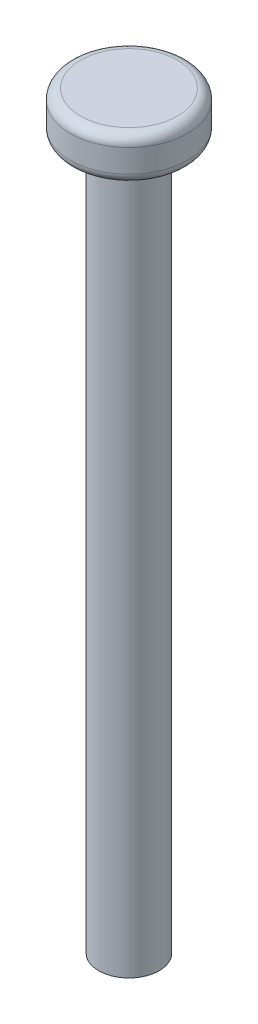
from build123d import *

# Parameters (mm, degrees)
SKETCH1_R           = 3
BOSS_EXTRUDE1_DEPTH = 70
SKETCH2_R           = 5.8
BOSS_EXTRUDE2_DEPTH = 4.3
FILLET1_R           = 1


with BuildPart() as part:
    # Sketch1 → Boss-Extrude1 (new body)
    with BuildSketch(Plane(origin=(0, 0, 0), x_dir=(1, 0, 0), z_dir=(0, 1, 0))):
        with Locations(Location((0, 0, 0), (0, 0, 270))):  # turned: the seam where the file's is
            Circle(SKETCH1_R)
    extrude(amount=BOSS_EXTRUDE1_DEPTH)

    # Sketch2 → Boss-Extrude2 (add)
    with BuildSketch(Plane(origin=(0, 70, 0), x_dir=(1, 0, 0), z_dir=(0, 1, 0))):
        with Locations(Location((0, 0, 0), (0, 0, 270))):  # turned: the seam where the file's is
            Circle(SKETCH2_R)
    extrude(amount=BOSS_EXTRUDE2_DEPTH)

    # Fillet1
    fillet1_edges = [part.edges().sort_by_distance(p)[0] for p in [
        (0, 70, -5.8),
        (0, 74.3, -5.8),
    ]]
    fillet(fillet1_edges, radius=FILLET1_R)


solid = part.part
